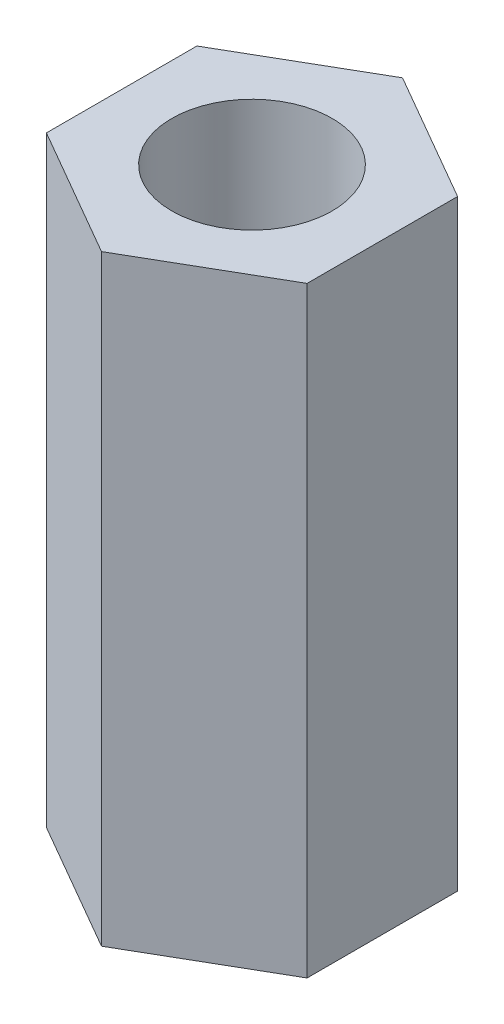
from build123d import *

# Parameters (mm, degrees)
SKETCH_1_R      = 4
EXTRUDE_1_DEPTH = 30


with BuildPart() as part:
    # Эскиз1 → Бобышка-Вытянуть1 (new body)
    with BuildSketch(Plane(origin=(0, 0, 0), x_dir=(1, 0, 0), z_dir=(0, 1, 0))):
        Polygon((0, 7.505553499), (-6.5, 3.75277675), (-6.5, -3.75277675), (0, -7.505553499), (6.5, -3.75277675), (6.5, 3.75277675), align=None)
        Circle(SKETCH_1_R, mode=Mode.SUBTRACT)
    extrude(amount=EXTRUDE_1_DEPTH)


solid = part.part
